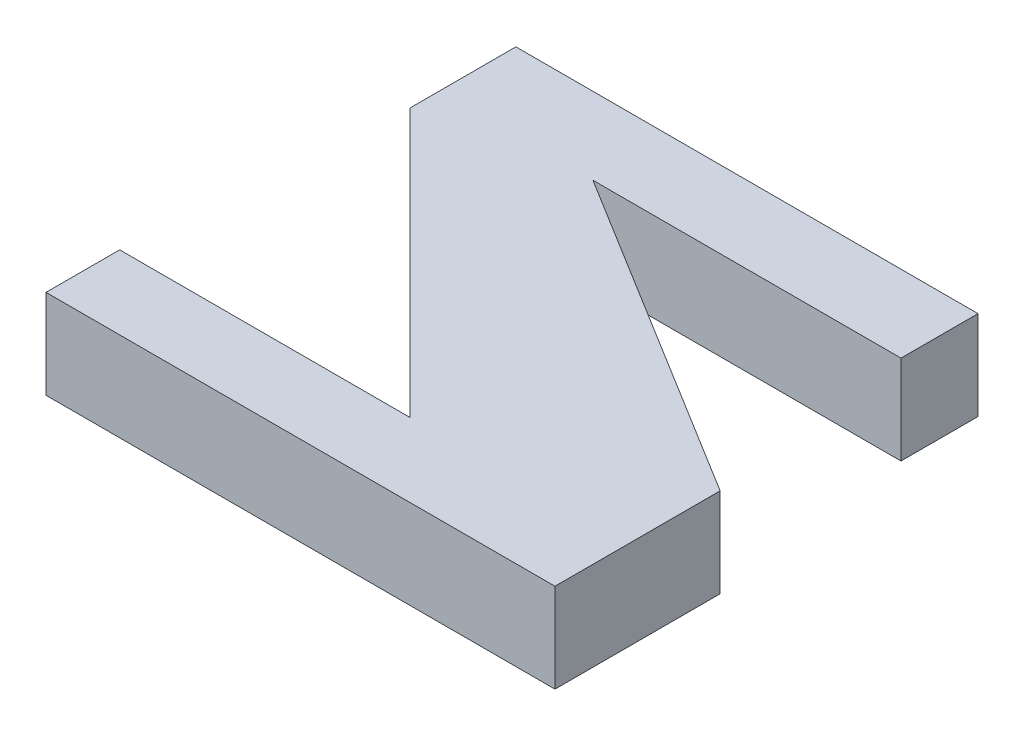
from build123d import *

# Parameters (mm, degrees)
BOSS_EXTRUDE1_DEPTH = 10


with BuildPart() as part:
    # Sketch1 → Boss-Extrude1 (new body)
    with BuildSketch(Plane(origin=(0, 0, 0), x_dir=(1, 0, 0), z_dir=(0, 1, 0))):
        Polygon((0, 0), (-51.830254463, 0), (-51.830254463, -11.893415879), (-21.783730136, -41.939940205), (-54.33413149, -41.939940205), (-54.33413149, -50.202734395), (2.75426473, -50.202734395), (2.75426473, -31.674044394), (-34.553502975, -8.638375744), (0, -8.638375744), align=None)
    extrude(amount=BOSS_EXTRUDE1_DEPTH)


solid = part.part
